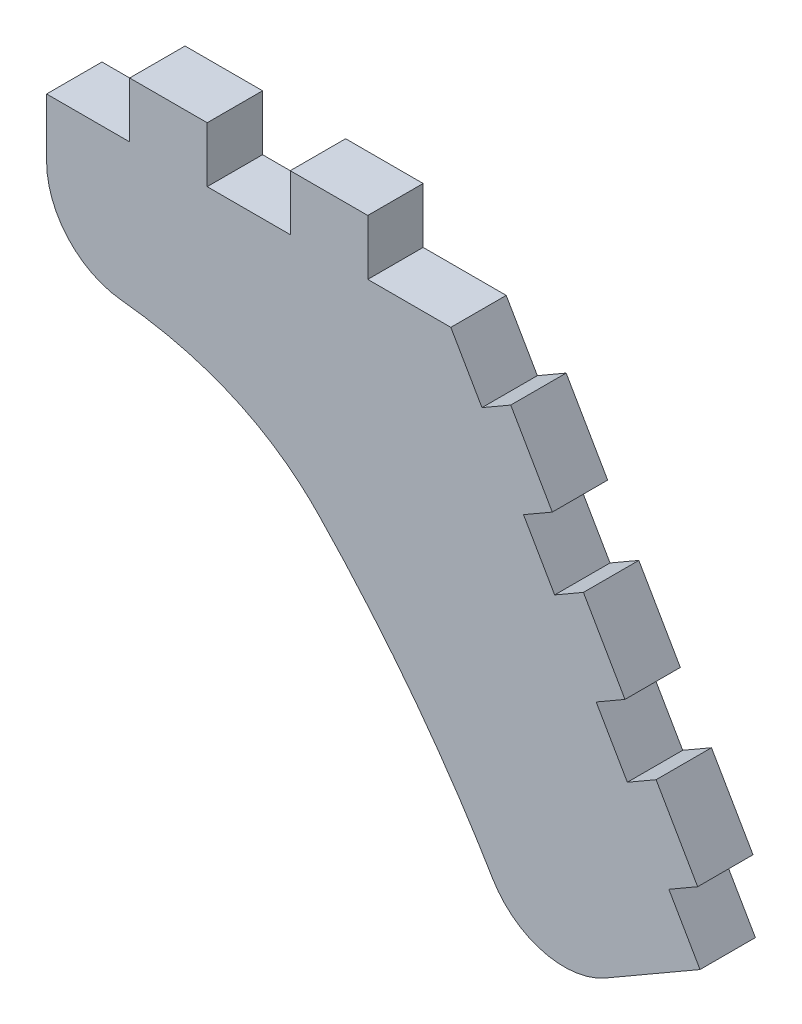
from build123d import *

# Parameters (mm, degrees)
BOSS_EXTRUDE1_DEPTH = 10
FILLET1_R           = 15


with BuildPart() as part:
    # Sketch1 → Boss-Extrude1 (new body)
    with BuildSketch(Plane.XY):
        with BuildLine():
            Line((0, 0), (15, 0))
            Line((15, 0), (15, 10))
            Line((15, 10), (29, 10))
            Line((29, 10), (29, 0))
            Line((29, 0), (44, 0))
            Line((44, 0), (44, 10))
            Line((44, 10), (58, 10))
            Line((58, 10), (58, 0))
            Line((58, 0), (73, 0))
            Line((73, 0), (78.625, -9.742785793))
            Line((78.625, -9.742785793), (83.821152423, -6.742785793))
            Line((83.821152423, -6.742785793), (91.321152423, -19.733166849))
            Line((91.321152423, -19.733166849), (86.125, -22.733166849))
            Line((86.125, -22.733166849), (91.75, -32.475952642))
            Line((91.75, -32.475952642), (96.946152423, -29.475952642))
            Line((96.946152423, -29.475952642), (104.446152423, -42.466333699))
            Line((104.446152423, -42.466333699), (99.25, -45.466333699))
            Line((99.25, -45.466333699), (104.875, -55.209119491))
            Line((104.875, -55.209119491), (110.071152423, -52.209119491))
            Line((110.071152423, -52.209119491), (117.571152423, -65.199500548))
            Line((117.571152423, -65.199500548), (112.375, -68.199500548))
            Line((112.375, -68.199500548), (118, -77.942286341))
            Line((118, -77.942286341), (87.689110868, -95.442286341))
            add(Edge.make_bspline(
                [(87.689110868, -95.442286341), (77.660181341, -75.620017272), (64.817303381, -57.569676854), (49.160476986, -41.291265088)],
                knots=[0, 0, 0, 0, 1, 1, 1, 1], degree=3))
            add(Edge.make_bspline(
                [(0, -25), (17.242534467, -24.639573707), (35.899987596, -27.504326339), (49.160476986, -41.291265088)],
                knots=[0, 0, 0, 0, 1, 1, 1, 1], degree=3))
            Line((0, -25), (0, 0))
        make_face()
    extrude(amount=BOSS_EXTRUDE1_DEPTH)

    # Fillet1
    fillet1_edges = [part.edges().sort_by_distance(p)[0] for p in [
        (87.689110868, -95.442286341, 5),
        (0, -25, 5),
    ]]
    fillet(fillet1_edges, radius=FILLET1_R)


solid = part.part
